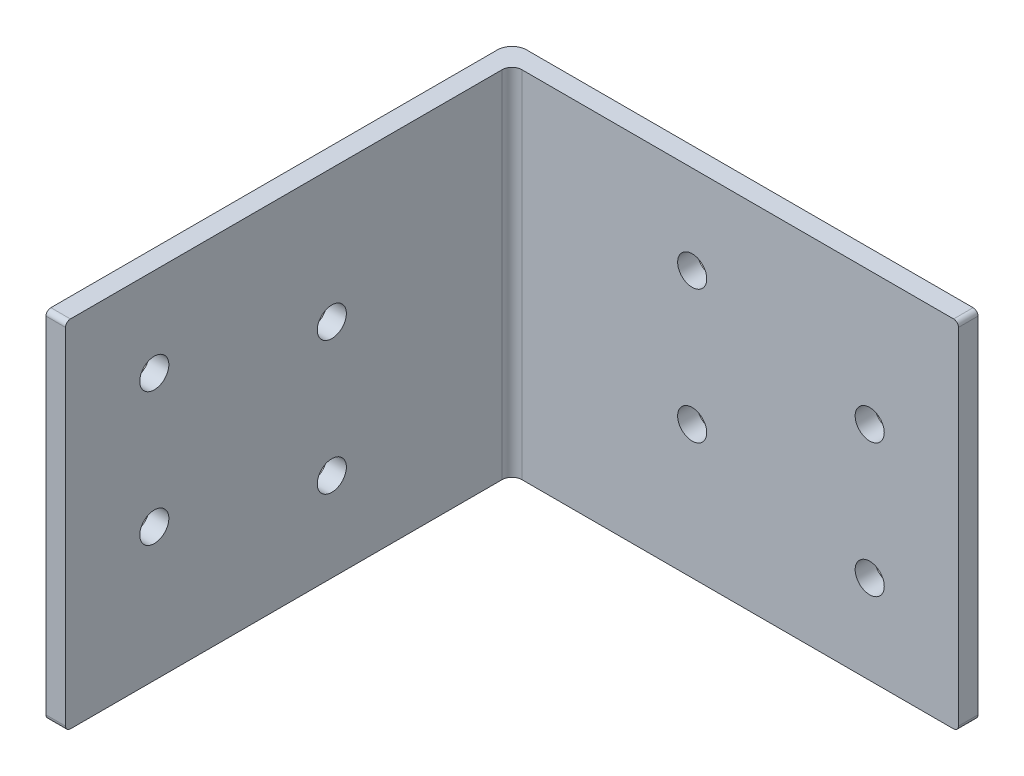
from build123d import *

# Parameters (mm, degrees)
BOSS_EXTRUDE1_DEPTH = 25.4
FILLET1_R           = 2.0955
FILLET2_R           = 1.397
FILLET3_R           = 0.6985
CUT_EXTRUDE1_REACH  = 4.794
SKETCH4_R           = 2.0828
CUT_EXTRUDE2_REACH  = 4.794
SKETCH5_R           = 2.0828


with BuildPart() as part:
    # Sketch3 → Boss-Extrude1 (new body, symmetric)
    with BuildSketch(Plane(origin=(0, 0, 0), x_dir=(1, 0, 0), z_dir=(0, 1, 0))):
        Polygon((1.397, -1.397), (65.278, -1.397), (65.278, 1.397), (-1.397, 1.397), (-1.397, -65.278), (1.397, -65.278), align=None)
    extrude(amount=BOSS_EXTRUDE1_DEPTH, both=True)

    # Fillet1
    fillet1_edges = [part.edges().sort_by_distance(p)[0] for p in [
        (-1.397, 0, -1.397),
    ]]
    fillet(fillet1_edges, radius=FILLET1_R)

    # Fillet2
    fillet2_edges = [part.edges().sort_by_distance(p)[0] for p in [
        (1.397, 0, 1.397),
    ]]
    fillet(fillet2_edges, radius=FILLET2_R)

    # Fillet3
    fillet3_edges = [part.edges().sort_by_distance(p)[0] for p in [
        (65.278, 25.4, 0),
        (0, 25.4, 65.278),
        (0, -25.4, 65.278),
        (65.278, -25.4, 0),
    ]]
    fillet(fillet3_edges, radius=FILLET3_R)

    # Sketch4 → Cut-Extrude1 (cut, up to next)
    with BuildSketch(Plane(origin=(1.397, 0, 0), x_dir=(0, 0, -1), z_dir=(1, 0, 0)), mode=Mode.PRIVATE) as cut_extrude1_sk1:
        with Locations((-52.578, -6.35)):
            Circle(SKETCH4_R)
    cut_extrude1_tool1 = extrude(cut_extrude1_sk1.sketch, amount=-CUT_EXTRUDE1_REACH, mode=Mode.PRIVATE) & part.part
    add(cut_extrude1_tool1.solids().sort_by_distance((1.397, -6.35, 52.578))[0], mode=Mode.SUBTRACT)
    # Sketch4 → Cut-Extrude1 (cut, up to next)
    with BuildSketch(Plane(origin=(1.397, 0, 0), x_dir=(0, 0, -1), z_dir=(1, 0, 0)), mode=Mode.PRIVATE) as cut_extrude1_sk2:
        with Locations((-27.178, 6.35)):
            Circle(SKETCH4_R)
    cut_extrude1_tool2 = extrude(cut_extrude1_sk2.sketch, amount=-CUT_EXTRUDE1_REACH, mode=Mode.PRIVATE) & part.part
    add(cut_extrude1_tool2.solids().sort_by_distance((1.397, 6.35, 27.178))[0], mode=Mode.SUBTRACT)
    # Sketch4 → Cut-Extrude1 (cut, up to next)
    with BuildSketch(Plane(origin=(1.397, 0, 0), x_dir=(0, 0, -1), z_dir=(1, 0, 0)), mode=Mode.PRIVATE) as cut_extrude1_sk3:
        with Locations((-27.178, -12.7)):
            Circle(SKETCH4_R)
    cut_extrude1_tool3 = extrude(cut_extrude1_sk3.sketch, amount=-CUT_EXTRUDE1_REACH, mode=Mode.PRIVATE) & part.part
    add(cut_extrude1_tool3.solids().sort_by_distance((1.397, -12.7, 27.178))[0], mode=Mode.SUBTRACT)
    # Sketch4 → Cut-Extrude1 (cut, up to next)
    with BuildSketch(Plane(origin=(1.397, 0, 0), x_dir=(0, 0, -1), z_dir=(1, 0, 0)), mode=Mode.PRIVATE) as cut_extrude1_sk4:
        with Locations((-52.578, 12.7)):
            Circle(SKETCH4_R)
    cut_extrude1_tool4 = extrude(cut_extrude1_sk4.sketch, amount=-CUT_EXTRUDE1_REACH, mode=Mode.PRIVATE) & part.part
    add(cut_extrude1_tool4.solids().sort_by_distance((1.397, 12.7, 52.578))[0], mode=Mode.SUBTRACT)

    # Sketch5 → Cut-Extrude2 (cut, up to next)
    with BuildSketch(Plane.XY.offset(1.397), mode=Mode.PRIVATE) as cut_extrude2_sk1:
        with Locations((27.178, 12.7)):
            Circle(SKETCH5_R)
    cut_extrude2_tool1 = extrude(cut_extrude2_sk1.sketch, amount=-CUT_EXTRUDE2_REACH, mode=Mode.PRIVATE) & part.part
    add(cut_extrude2_tool1.solids().sort_by_distance((27.178, 12.7, 1.397))[0], mode=Mode.SUBTRACT)
    # Sketch5 → Cut-Extrude2 (cut, up to next)
    with BuildSketch(Plane.XY.offset(1.397), mode=Mode.PRIVATE) as cut_extrude2_sk2:
        with Locations((27.178, -6.35)):
            Circle(SKETCH5_R)
    cut_extrude2_tool2 = extrude(cut_extrude2_sk2.sketch, amount=-CUT_EXTRUDE2_REACH, mode=Mode.PRIVATE) & part.part
    add(cut_extrude2_tool2.solids().sort_by_distance((27.178, -6.35, 1.397))[0], mode=Mode.SUBTRACT)
    # Sketch5 → Cut-Extrude2 (cut, up to next)
    with BuildSketch(Plane.XY.offset(1.397), mode=Mode.PRIVATE) as cut_extrude2_sk3:
        with Locations((52.578, -12.7)):
            Circle(SKETCH5_R)
    cut_extrude2_tool3 = extrude(cut_extrude2_sk3.sketch, amount=-CUT_EXTRUDE2_REACH, mode=Mode.PRIVATE) & part.part
    add(cut_extrude2_tool3.solids().sort_by_distance((52.578, -12.7, 1.397))[0], mode=Mode.SUBTRACT)
    # Sketch5 → Cut-Extrude2 (cut, up to next)
    with BuildSketch(Plane.XY.offset(1.397), mode=Mode.PRIVATE) as cut_extrude2_sk4:
        with Locations((52.578, 6.35)):
            Circle(SKETCH5_R)
    cut_extrude2_tool4 = extrude(cut_extrude2_sk4.sketch, amount=-CUT_EXTRUDE2_REACH, mode=Mode.PRIVATE) & part.part
    add(cut_extrude2_tool4.solids().sort_by_distance((52.578, 6.35, 1.397))[0], mode=Mode.SUBTRACT)


solid = part.part
